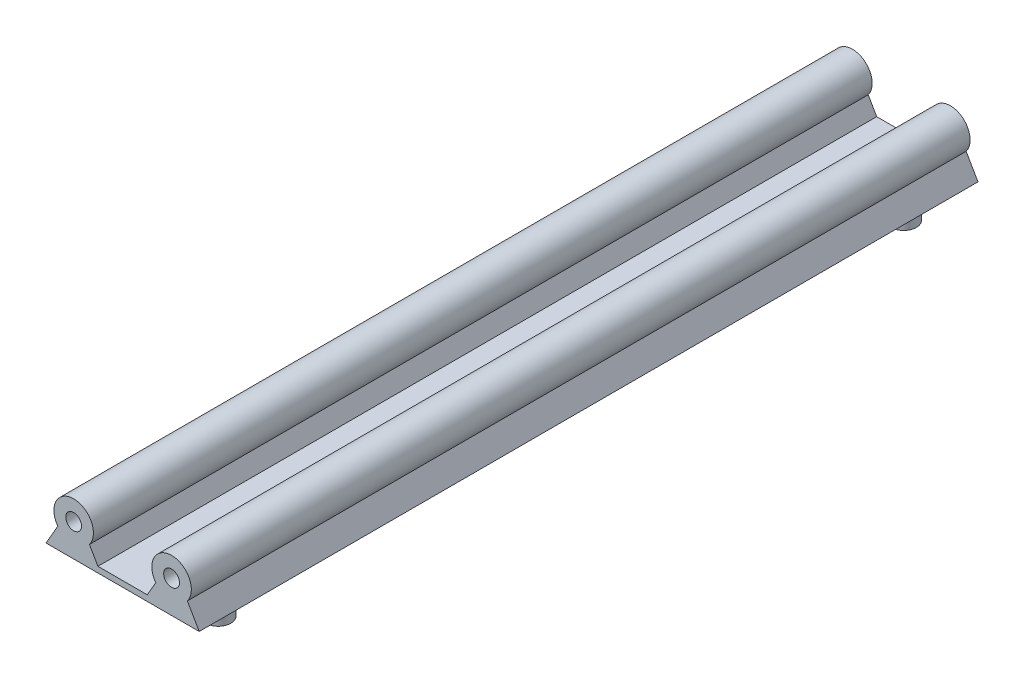
from build123d import *

# Parameters (mm, degrees)
SKETCH1_R           = 5
BOSS_EXTRUDE1_DEPTH = 220
SKETCH4_R           = 3.2
BOSS_EXTRUDE3_DEPTH = 6
BOSS_EXTRUDE4_DEPTH = 220
SKETCH5_R           = 1.37
CUT_EXTRUDE1_DEPTH  = 7
SKETCH6_R           = 1.37
CUT_EXTRUDE2_DEPTH  = 7
SKETCH7_R           = 3.2
CUT_EXTRUDE3_DEPTH  = 6
CUT_EXTRUDE4_DEPTH  = 11.4
SKETCH10_R          = 2
CUT_EXTRUDE5_DEPTH  = 7
CUT_EXTRUDE6_DEPTH  = 11.4
SKETCH12_R          = 2
CUT_EXTRUDE7_DEPTH  = 7


with BuildPart() as part:
    # Sketch1 → Boss-Extrude1 (new body)
    with BuildSketch(Plane.XY):
        Circle(SKETCH1_R)
        with BuildLine():
            Line((-4, -3), (-7, -8.196152423))
            Line((-7, -8.196152423), (7, -8.196152423))
            Line((7, -8.196152423), (4, -3))
            ThreePointArc((4, -3), (0, 5), (-4, -3))
        make_face()
        with BuildLine():
            Line((28.8, -3), (31.8, -8.196152423))
            Line((31.8, -8.196152423), (17.8, -8.196152423))
            Line((17.8, -8.196152423), (20.8, -3))
            ThreePointArc((20.8, -3), (24.8, 5), (28.8, -3))
        make_face()
    extrude(amount=BOSS_EXTRUDE1_DEPTH)

    # Sketch4 → Boss-Extrude3 (add)
    with BuildSketch(Plane.XZ.offset(8.196152423)):
        with Locations((0, 196.8)):
            Circle(SKETCH4_R)
        with Locations((24.8, 196.8)):
            Circle(SKETCH4_R)
        with Locations((24.8, 172)):
            Circle(SKETCH4_R)
        with Locations((24.8, 147.2)):
            Circle(SKETCH4_R)
        with Locations((24.8, 122.4)):
            Circle(SKETCH4_R)
        with Locations((24.8, 97.6)):
            Circle(SKETCH4_R)
        with Locations((24.8, 72.8)):
            Circle(SKETCH4_R)
        with Locations((24.8, 48)):
            Circle(SKETCH4_R)
        with Locations((24.8, 23.2)):
            Circle(SKETCH4_R)
        with Locations((0, 172)):
            Circle(SKETCH4_R)
        with Locations((0, 147.2)):
            Circle(SKETCH4_R)
        with Locations((0, 122.4)):
            Circle(SKETCH4_R)
        with Locations((0, 97.6)):
            Circle(SKETCH4_R)
        with Locations((0, 72.8)):
            Circle(SKETCH4_R)
        with Locations((0, 48)):
            Circle(SKETCH4_R)
        with Locations((0, 23.2)):
            Circle(SKETCH4_R)
    extrude(amount=BOSS_EXTRUDE3_DEPTH)

    # Sketch3 → Boss-Extrude4 (add)
    with BuildSketch(Plane.XY.offset(220)):
        Polygon((7, -8.196152423), (17.8, -8.196152423), (18.65, -8.196152423), (18.65, -6.723909236), (6.15, -6.723909236), (6.15, -8.196152423), align=None)
    extrude(amount=-BOSS_EXTRUDE4_DEPTH)

    # Sketch5 → Cut-Extrude1 (cut)
    with BuildSketch(Plane(origin=(0, 0, 0), x_dir=(-1, 0, 0), z_dir=(0, 0, -1))):
        Circle(SKETCH5_R)
        with Locations((-24.8, 0)):
            Circle(SKETCH5_R)
    extrude(amount=-CUT_EXTRUDE1_DEPTH, mode=Mode.SUBTRACT)

    # Sketch6 → Cut-Extrude2 (cut)
    with BuildSketch(Plane.XY.offset(220)):
        Circle(SKETCH6_R)
        with Locations((24.8, 0)):
            Circle(SKETCH6_R)
    extrude(amount=-CUT_EXTRUDE2_DEPTH, mode=Mode.SUBTRACT)

    # Sketch7 → Cut-Extrude3 (cut)
    with BuildSketch(Plane.XZ.offset(14.196152423)):
        with Locations((0, 172)):
            Circle(SKETCH7_R)
        with Locations((24.8, 172)):
            Circle(SKETCH7_R)
        with Locations((24.8, 147.2)):
            Circle(SKETCH7_R)
        with Locations((24.8, 122.4)):
            Circle(SKETCH7_R)
        with Locations((24.8, 97.6)):
            Circle(SKETCH7_R)
        with Locations((24.8, 72.8)):
            Circle(SKETCH7_R)
        with Locations((24.8, 48)):
            Circle(SKETCH7_R)
        with Locations((0, 147.2)):
            Circle(SKETCH7_R)
        with Locations((0, 122.4)):
            Circle(SKETCH7_R)
        with Locations((0, 97.6)):
            Circle(SKETCH7_R)
        with Locations((0, 72.8)):
            Circle(SKETCH7_R)
        with Locations((0, 48)):
            Circle(SKETCH7_R)
    extrude(amount=-CUT_EXTRUDE3_DEPTH, mode=Mode.SUBTRACT)

    # Sketch9 → Cut-Extrude4 (cut)
    with BuildSketch(Plane(origin=(0, 0, 0), x_dir=(-1, 0, 0), z_dir=(0, 0, -1))):
        with BuildLine():
            Line((4, -3), (7, -8.196152423))
            Line((7, -8.196152423), (-31.8, -8.196152423))
            Line((-31.8, -8.196152423), (-28.8, -3))
            ThreePointArc((-28.8, -3), (-24.8, 5), (-20.8, -3))
            Line((-20.8, -3), (-18.65, -6.723909236))
            Line((-18.65, -6.723909236), (-6.15, -6.723909236))
            Line((-6.15, -6.723909236), (-4, -3))
            ThreePointArc((-4, -3), (0, 5), (4, -3))
        make_face()
    extrude(amount=-CUT_EXTRUDE4_DEPTH, mode=Mode.SUBTRACT)

    # Sketch10 → Cut-Extrude5 (cut)
    with BuildSketch(Plane(origin=(0, 0, 11.4), x_dir=(-1, 0, 0), z_dir=(0, 0, -1))):
        with Locations((-24.8, 0)):
            Circle(SKETCH10_R)
        Circle(SKETCH10_R)
    extrude(amount=-CUT_EXTRUDE5_DEPTH, mode=Mode.SUBTRACT)

    # Sketch11 → Cut-Extrude6 (cut)
    with BuildSketch(Plane.XY.offset(220)):
        with BuildLine():
            Line((20.8, -3), (18.65, -6.723909236))
            Line((18.65, -6.723909236), (6.15, -6.723909236))
            Line((6.15, -6.723909236), (4, -3))
            ThreePointArc((4, -3), (0, 5), (-4, -3))
            Line((-4, -3), (-7, -8.196152423))
            Line((-7, -8.196152423), (31.8, -8.196152423))
            Line((31.8, -8.196152423), (28.8, -3))
            ThreePointArc((28.8, -3), (24.8, 5), (20.8, -3))
        make_face()
    extrude(amount=-CUT_EXTRUDE6_DEPTH, mode=Mode.SUBTRACT)

    # Sketch12 → Cut-Extrude7 (cut)
    with BuildSketch(Plane.XY.offset(208.6)):
        Circle(SKETCH12_R)
        with Locations((24.8, 0)):
            Circle(SKETCH12_R)
    extrude(amount=-CUT_EXTRUDE7_DEPTH, mode=Mode.SUBTRACT)


solid = part.part
